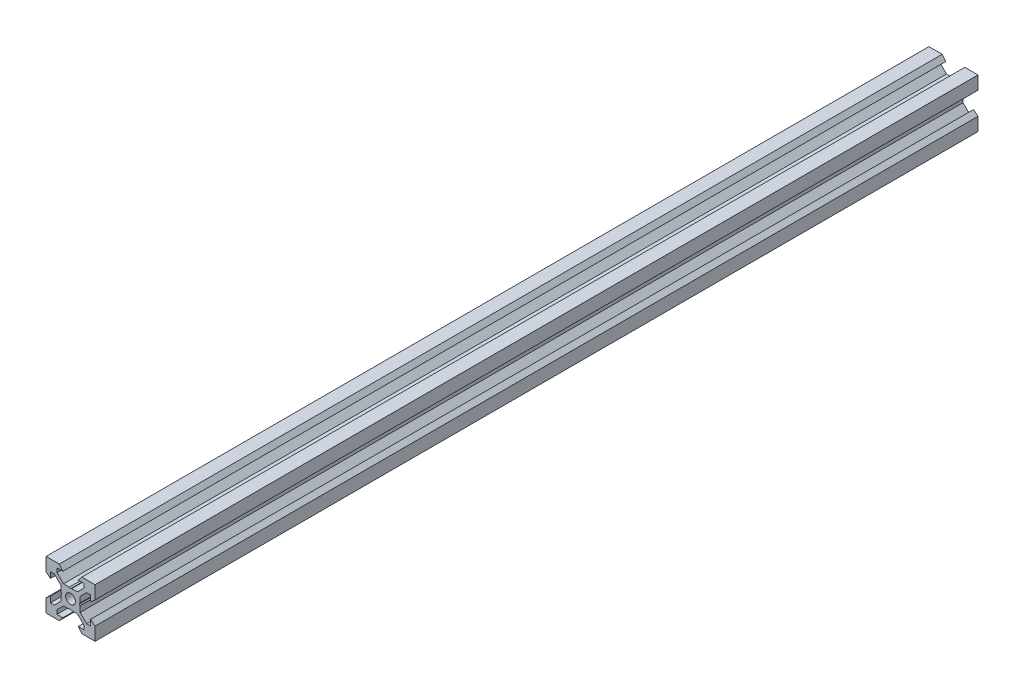
from build123d import *

# Parameters (mm, degrees)
SKETCH1_R           = 2
BOSS_EXTRUDE1_DEPTH = 180


with BuildPart() as part:
    # Sketch1 → Boss-Extrude1 (new body, symmetric)
    with BuildSketch(Plane.XY):
        Polygon((10, 10), (10, 4.610379336), (8.2, 3.1), (8.2, 5.5), (6.560660172, 5.5), (3.9, 2.839339828), (3.9, 0.519615242), (3.6, 0), (3.9, -0.519615242), (3.9, -2.839339828), (6.560660172, -5.5), (8.2, -5.5), (8.2, -3.1), (10, -4.610379336), (10, -10), (4.610379336, -10), (3.1, -8.2), (5.5, -8.2), (5.5, -6.560660172), (2.839339828, -3.9), (0.519615242, -3.9), (0, -3.6), (-0.519615242, -3.9), (-2.839339828, -3.9), (-5.5, -6.560660172), (-5.5, -8.2), (-3.1, -8.2), (-4.610379336, -10), (-10, -10), (-10, -4.610379336), (-8.2, -3.1), (-8.2, -5.5), (-6.560660172, -5.5), (-3.9, -2.839339828), (-3.9, -0.519615242), (-3.6, 0), (-3.9, 0.519615242), (-3.9, 2.839339828), (-6.560660172, 5.5), (-8.2, 5.5), (-8.2, 3.1), (-10, 4.610379336), (-10, 10), (-4.610379336, 10), (-3.1, 8.2), (-5.5, 8.2), (-5.5, 6.560660172), (-2.839339828, 3.9), (-0.519615242, 3.9), (0, 3.6), (0.519615242, 3.9), (2.839339828, 3.9), (5.5, 6.560660172), (5.5, 8.2), (3.1, 8.2), (4.610379336, 10), align=None)
        Circle(SKETCH1_R, mode=Mode.SUBTRACT)
    extrude(amount=BOSS_EXTRUDE1_DEPTH, both=True)


solid = part.part
